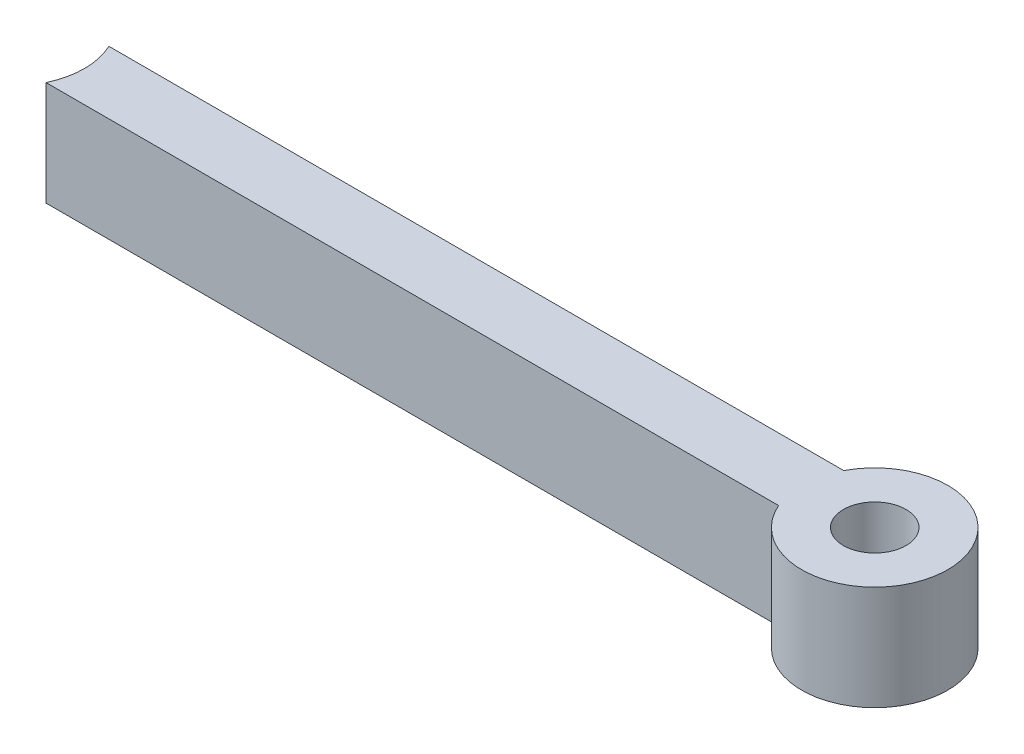
from build123d import *

# Parameters (mm, degrees)
BOSS_EXTRU_2_DEPTH      = 100
ESQUISSE5_R             = 30
ENL_V_MAT_EXTRU_4_DEPTH = 101
ESQUISSE6_R             = 70
ENL_V_MAT_EXTRU_5_DEPTH = 101


with BuildPart() as part:
    # Esquisse1 → Boss.-Extru.2 (new body)
    with BuildSketch(Plane(origin=(0, 0, 0), x_dir=(1, 0, 0), z_dir=(0, 1, 0))):
        with BuildLine():
            Line((379.401849177, 30.095541494), (-327.704932009, 30.095541494))
            Line((-327.704932009, 30.095541494), (-327.704932009, -30.095541494))
            Line((-327.704932009, -30.095541494), (377.209706533, -30.095541494))
            ThreePointArc((377.209706533, -30.095541494), (511.408174051, -4.847552565), (379.401849177, 30.095541494))
        make_face()
    extrude(amount=BOSS_EXTRU_2_DEPTH)

    # Esquisse5 → Enlèv. mat.-Extru.4 (cut, through all)
    with BuildSketch(Plane(origin=(0, 100, 0), x_dir=(1, 0, 0), z_dir=(0, 1, 0))):
        with Locations((441.45455179, -2.299860933)):
            Circle(ESQUISSE5_R)
    extrude(amount=-ENL_V_MAT_EXTRU_4_DEPTH, mode=Mode.SUBTRACT)

    # Esquisse6 → Enlèv. mat.-Extru.5 (cut, through all)
    with BuildSketch(Plane(origin=(0, 100, 0), x_dir=(1, 0, 0), z_dir=(0, 1, 0))):
        with Locations((-387.729757148, 0)):
            Circle(ESQUISSE6_R)
    extrude(amount=-ENL_V_MAT_EXTRU_5_DEPTH, mode=Mode.SUBTRACT)


solid = part.part
